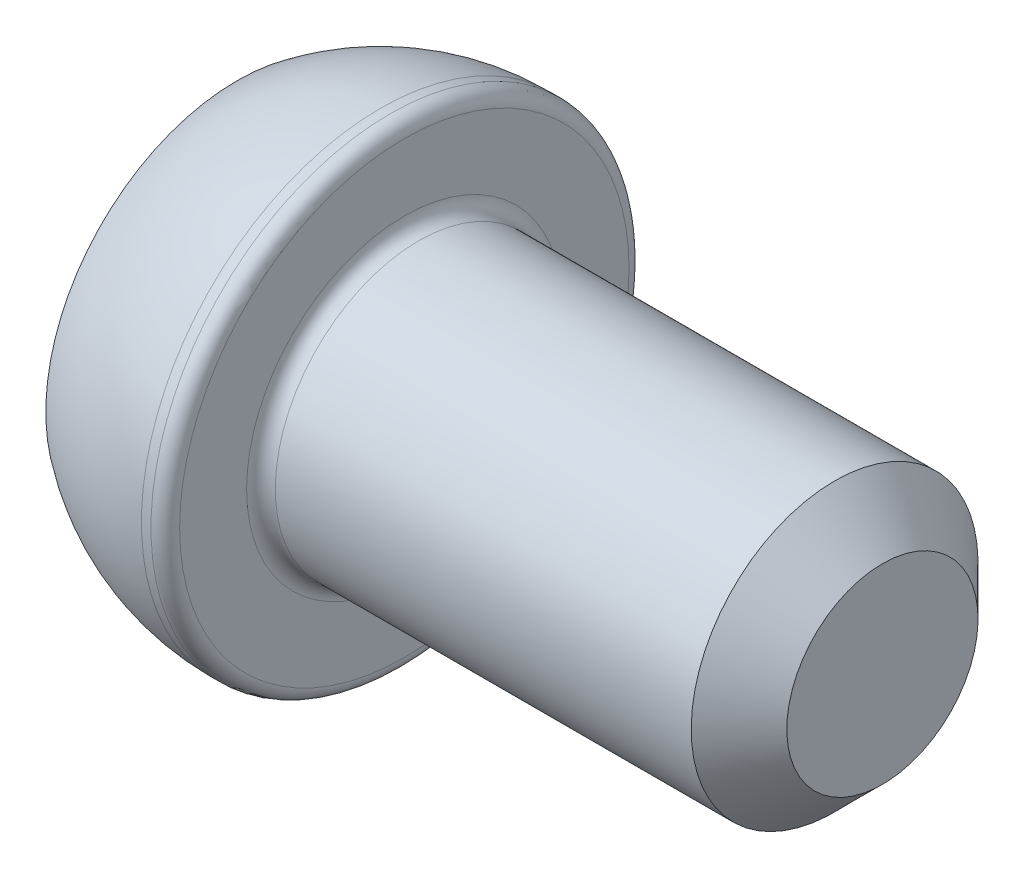
from build123d import *

# Parameters (mm, degrees)
CUT_EXTRUDE_1_DEPTH = 2
FILLET_1_R          = 0.3
CHAMFER_1_SIZE      = 1


with BuildPart() as part:
    # Эскиз1 → Повернуть1 (revolve)
    with BuildSketch(Plane.XY):
        with BuildLine():
            Line((0, 0), (0, 4))
            ThreePointArc((0, 4), (1.41886117, 4.74341649), (3, 5))
            Line((3, 5), (3.5, 5))
            Line((3.5, 5), (3.5, 3))
            Line((3.5, 3), (13.5, 3))
            Line((13.5, 3), (13.5, 0))
            Line((13.5, 0), (0, 0))
        make_face()
    revolve(axis=Axis((13.5, 0, 0), (-1, 0, 0)))

    # Эскиз2 → Вырез-Вытянуть1 (cut)
    with BuildSketch(Plane.ZY):
        Polygon((1.154700538, 2), (-1.154700538, 2), (-2.309401077, 0), (-1.154700538, -2), (1.154700538, -2), (2.309401077, 0), align=None)
    extrude(amount=-CUT_EXTRUDE_1_DEPTH, mode=Mode.SUBTRACT)

    # Скругление1
    fillet_1_edges = [part.edges().sort_by_distance(p)[0] for p in [
        (3.5, -3, 0),
        (3.5, -5, 0),
    ]]
    fillet(fillet_1_edges, radius=FILLET_1_R)

    # Фаска1
    chamfer_1_edges = [part.edges().sort_by_distance(p)[0] for p in [
        (13.5, -3, 0),
    ]]
    chamfer(chamfer_1_edges, length=CHAMFER_1_SIZE)


solid = part.part
